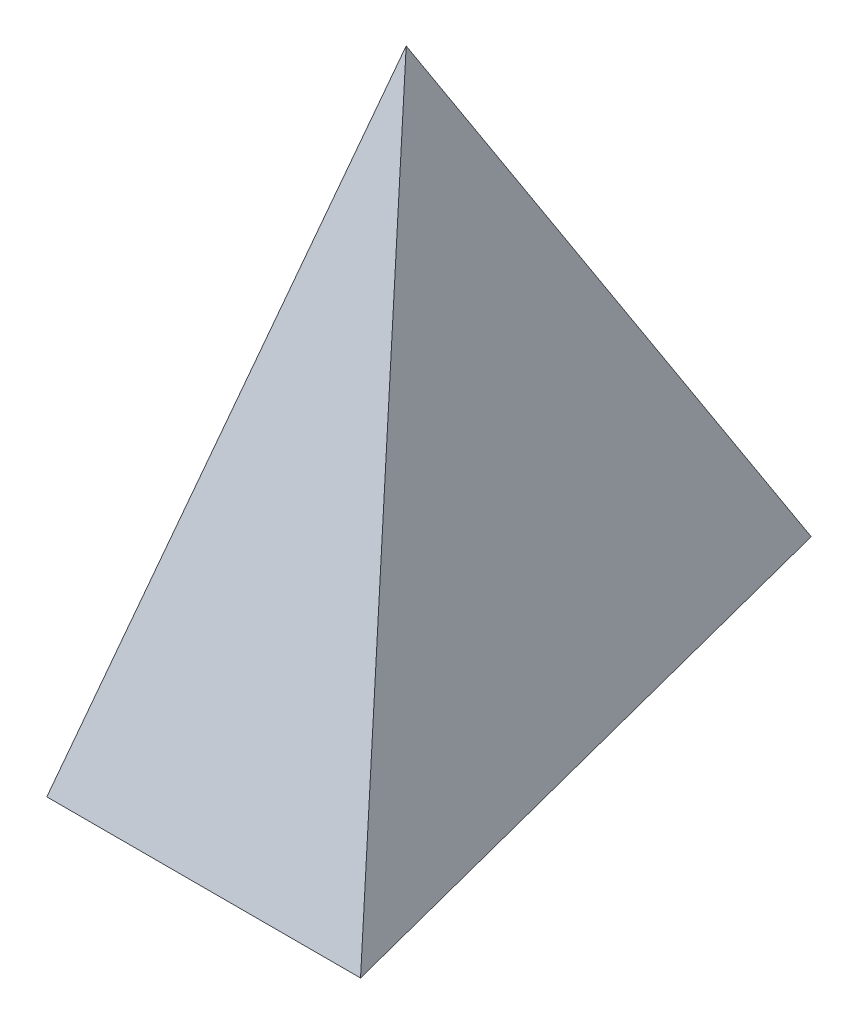
from build123d import *


with BuildPart() as part:
    # Sketch1 → Loft1 section 0
    with BuildSketch(Plane(origin=(0, 0, 0), x_dir=(1, 0, 0), z_dir=(0, 1, 0)), mode=Mode.PRIVATE) as loft1_s0:
        Polygon((0, 0), (10, 0), (5, 19.364916731), align=None)
    loft([Vertex(5, 20, -6.454972244), loft1_s0.sketch])


solid = part.part
